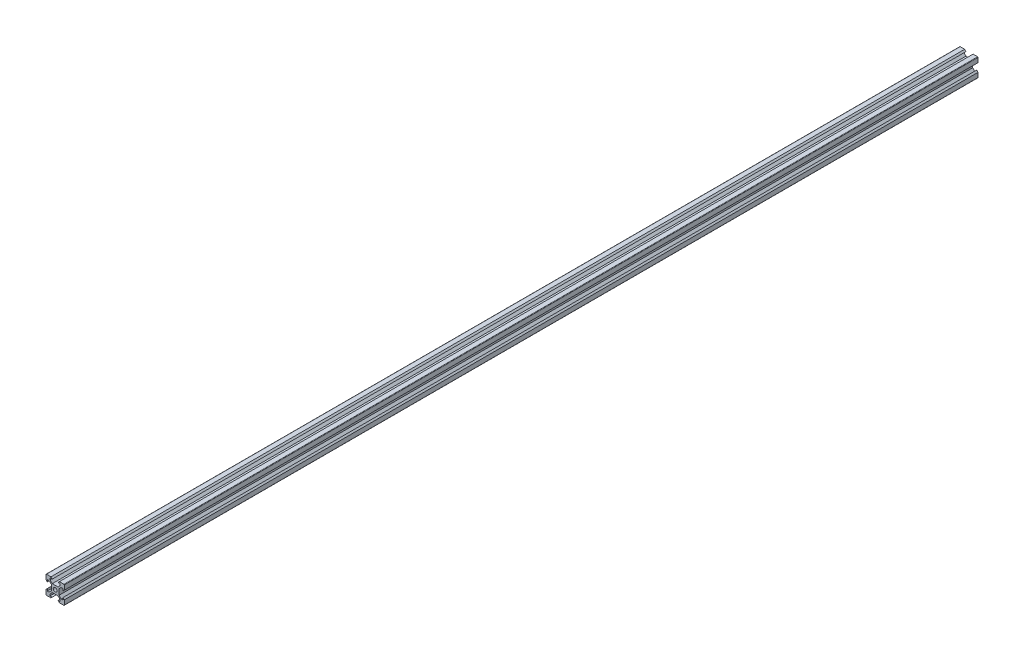
from build123d import *

# Parameters (mm, degrees)
SKETCH1_R           = 2.1
BOSS_EXTRUDE1_DEPTH = 1000


with BuildPart() as part:
    # Sketch1 → Boss-Extrude1 (new body)
    with BuildSketch(Plane.XY):
        with BuildLine():
            Line((-3.125, 4.245), (3.125, 4.245))
            Line((3.125, 4.245), (5.5, 6.62))
            Line((5.5, 6.62), (5.5, 8.545))
            Line((5.5, 8.545), (3.125, 8.545))
            Line((3.125, 8.545), (4.58, 10))
            Line((4.58, 10), (9.5, 10))
            ThreePointArc((9.5, 10), (9.853553391, 9.853553391), (10, 9.5))
            Line((10, 9.5), (10, 4.58))
            Line((10, 4.58), (8.545, 3.125))
            Line((8.545, 3.125), (8.545, 5.5))
            Line((8.545, 5.5), (6.62, 5.5))
            Line((6.62, 5.5), (4.245, 3.125))
            Line((4.245, 3.125), (4.245, -3.125))
            Line((4.245, -3.125), (6.62, -5.5))
            Line((6.62, -5.5), (8.545, -5.5))
            Line((8.545, -5.5), (8.545, -3.125))
            Line((8.545, -3.125), (10, -4.58))
            Line((10, -4.58), (10, -9.5))
            ThreePointArc((10, -9.5), (9.853553391, -9.853553391), (9.5, -10))
            Line((9.5, -10), (4.58, -10))
            Line((4.58, -10), (3.125, -8.545))
            Line((3.125, -8.545), (5.5, -8.545))
            Line((5.5, -8.545), (5.5, -6.62))
            Line((5.5, -6.62), (3.125, -4.245))
            Line((3.125, -4.245), (-3.125, -4.245))
            Line((-3.125, -4.245), (-5.5, -6.62))
            Line((-5.5, -6.62), (-5.5, -8.545))
            Line((-5.5, -8.545), (-3.125, -8.545))
            Line((-3.125, -8.545), (-4.58, -10))
            Line((-4.58, -10), (-9.5, -10))
            ThreePointArc((-9.5, -10), (-9.853553391, -9.853553391), (-10, -9.5))
            Line((-10, -9.5), (-10, -4.58))
            Line((-10, -4.58), (-8.545, -3.125))
            Line((-8.545, -3.125), (-8.545, -5.5))
            Line((-8.545, -5.5), (-6.62, -5.5))
            Line((-6.62, -5.5), (-4.245, -3.125))
            Line((-4.245, -3.125), (-4.245, 3.125))
            Line((-4.245, 3.125), (-6.62, 5.5))
            Line((-6.62, 5.5), (-8.545, 5.5))
            Line((-8.545, 5.5), (-8.545, 3.125))
            Line((-8.545, 3.125), (-10, 4.58))
            Line((-10, 4.58), (-10, 9.5))
            ThreePointArc((-10, 9.5), (-9.853553391, 9.853553391), (-9.5, 10))
            Line((-9.5, 10), (-4.58, 10))
            Line((-4.58, 10), (-3.125, 8.545))
            Line((-3.125, 8.545), (-5.5, 8.545))
            Line((-5.5, 8.545), (-5.5, 6.62))
            Line((-5.5, 6.62), (-3.125, 4.245))
        make_face()
        Circle(SKETCH1_R, mode=Mode.SUBTRACT)
    extrude(amount=BOSS_EXTRUDE1_DEPTH)


solid = part.part
